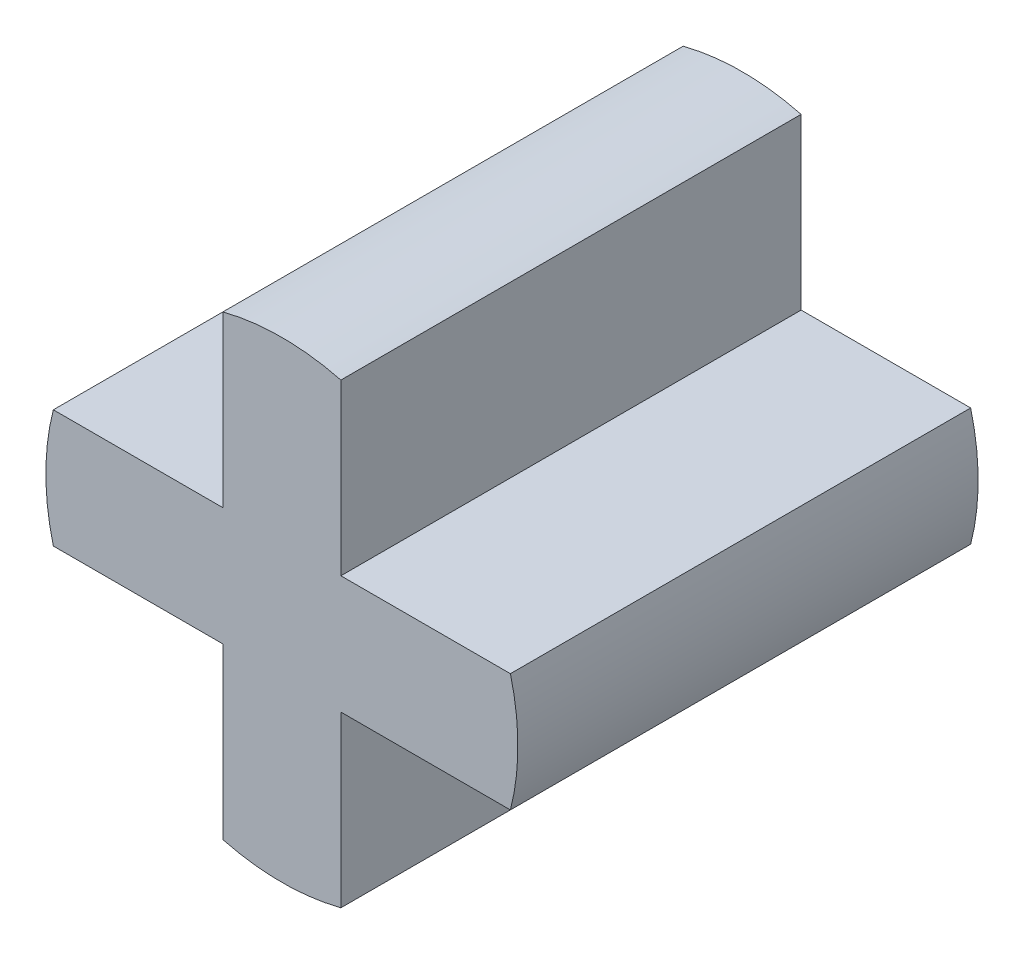
from build123d import *

# Parameters (mm, degrees)
BOSS_EXTRUDE1_DEPTH = 7.8


with BuildPart() as part:
    # Sketch3 → Boss-Extrude1 (new body)
    with BuildSketch(Plane.XY):
        with BuildLine():
            Line((-1, 1), (-3.872983346, 1))
            ThreePointArc((-3.872983346, 1), (-4, 0), (-3.872983346, -1))
            Line((-3.872983346, -1), (-1, -1))
            Line((-1, -1), (-1, -3.872983346))
            ThreePointArc((-1, -3.872983346), (0, -4), (1, -3.872983346))
            Line((1, -3.872983346), (1, -1))
            Line((1, -1), (3.872983346, -1))
            ThreePointArc((3.872983346, -1), (4, 0), (3.872983346, 1))
            Line((3.872983346, 1), (1, 1))
            Line((1, 1), (1, 3.872983346))
            ThreePointArc((1, 3.872983346), (0, 4), (-1, 3.872983346))
            Line((-1, 3.872983346), (-1, 1))
        make_face()
    extrude(amount=BOSS_EXTRUDE1_DEPTH)


solid = part.part
